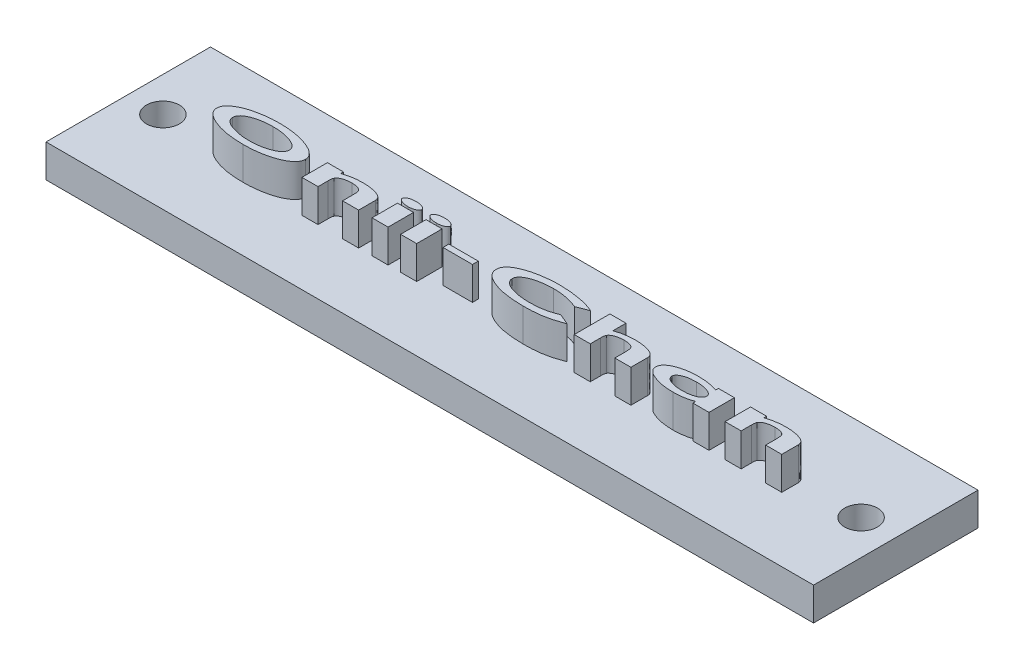
from build123d import *

# Parameters (mm, degrees)
SKETCH3_W           = 70
SKETCH3_H           = 15
BOSS_EXTRUDE2_DEPTH = 3
SKETCH4_W           = 1.465384615
SKETCH4_H           = 2.320192308
SKETCH4_W_2         = 2.686538461
SKETCH4_H_2         = 0.529166666
BOSS_EXTRUDE3_DEPTH = 3
CUT_EXTRUDE1_DEPTH  = 3


with BuildPart() as part:
    # Sketch3 → Boss-Extrude2 (new body)
    with BuildSketch(Plane(origin=(0, 0, 0), x_dir=(1, 0, 0), z_dir=(0, 1, 0))):
        Rectangle(SKETCH3_W, SKETCH3_H)
    extrude(amount=BOSS_EXTRUDE2_DEPTH)

    # Sketch4 → Boss-Extrude3 (add)
    with BuildSketch(Plane(origin=(0, 3, 0), x_dir=(1, 0, 0), z_dir=(0, 1, 0))):
        with BuildLine():
            add(Edge.make_bspline(
                [(-22.825846191, 1.629736401), (-22.757576293, 1.629374686), (-22.622072425, 1.628656742), (-22.420627484, 1.622767894), (-22.222784263, 1.613313748), (-22.028752902, 1.599985882), (-21.838329126, 1.582800798), (-21.651494379, 1.561901541), (-21.468068408, 1.537041789), (-21.288416269, 1.508604489), (-21.11242193, 1.476023598), (-20.940187047, 1.439906436), (-20.771392926, 1.399739372), (-20.606143448, 1.355981818), (-20.444525265, 1.308278732), (-20.286710423, 1.256789692), (-20.132543975, 1.201350028), (-19.982823493, 1.142566676), (-19.839183362, 1.081606322), (-19.704420123, 1.01784352), (-19.578383841, 0.953269033), (-19.46255587, 0.885630247), (-19.354796082, 0.818048497), (-19.257595324, 0.747061496), (-19.168943381, 0.67547058), (-19.089274699, 0.602102951), (-19.019683423, 0.526524233), (-18.958134502, 0.44996964), (-18.907486128, 0.370746496), (-18.864755173, 0.290415565), (-18.832412655, 0.207921761), (-18.808498405, 0.124096231), (-18.793989339, 0.038291112), (-18.792390068, -0.01961446), (-18.791586376, -0.048714119)],
                knots=[0, 0, 0, 0, 0.000204807, 0.000406505, 0.000604537, 0.000798981, 0.000989924, 0.001178088, 0.001362933, 0.001545187, 0.0017237, 0.001899832, 0.002073074, 0.002244163, 0.002412607, 0.002578539, 0.002742099, 0.002904026, 0.00306103, 0.003210114, 0.003351208, 0.003485715, 0.003612397, 0.00373262, 0.003846554, 0.003954116, 0.004057184, 0.004154528, 0.004248384, 0.00433885, 0.004427076, 0.004513654, 0.004600021, 0.004687269, 0.004687269, 0.004687269, 0.004687269], degree=3))
            add(Edge.make_bspline(
                [(-18.791586376, -0.048714119), (-18.792385512, -0.077393448), (-18.793981574, -0.134672739), (-18.808666166, -0.219519636), (-18.831696145, -0.302811901), (-18.863568531, -0.384591507), (-18.905214307, -0.464514415), (-18.956803822, -0.542013232), (-19.015947485, -0.618853731), (-19.085098278, -0.69335278), (-19.163837502, -0.765645989), (-19.251019028, -0.837232258), (-19.348097378, -0.905924498), (-19.453261674, -0.974687167), (-19.568351789, -1.040114017), (-19.692264151, -1.104569155), (-19.825198233, -1.167574579), (-19.966939336, -1.227853291), (-20.114761842, -1.286362895), (-20.267780806, -1.340024133), (-20.424157538, -1.39112695), (-20.584713055, -1.438235), (-20.749145411, -1.481234079), (-20.917482405, -1.520932162), (-21.089813158, -1.556116979), (-21.265878623, -1.589064461), (-21.446089108, -1.616420668), (-21.630019602, -1.641862794), (-21.818034284, -1.661467152), (-22.009846259, -1.679295187), (-22.20564539, -1.691400339), (-22.405358766, -1.701186388), (-22.60892962, -1.706992203), (-22.745916419, -1.707717938), (-22.815033892, -1.708084111)],
                knots=[0, 0, 0, 0, 8.5978e-05, 0.000171718, 0.000257512, 0.000344913, 0.000434521, 0.00052731, 0.000623869, 0.00072514, 0.000831804, 0.00094435, 0.001063312, 0.00118839, 0.001321159, 0.001460267, 0.001607353, 0.001762354, 0.001922272, 0.002084206, 0.002248732, 0.002415776, 0.002586088, 0.002758565, 0.002934567, 0.003113705, 0.00329586, 0.003481336, 0.003670694, 0.003862904, 0.00405921, 0.004259147, 0.004462753, 0.004670104, 0.004670104, 0.004670104, 0.004670104], degree=3))
            add(Edge.make_bspline(
                [(-22.815033892, -1.708084111), (-22.887332117, -1.70773091), (-23.030467403, -1.707031644), (-23.242929166, -1.701055372), (-23.450771295, -1.691932197), (-23.653857906, -1.677494606), (-23.852369851, -1.660595817), (-24.046453066, -1.639767549), (-24.235808577, -1.614314616), (-24.42042837, -1.584778074), (-24.600451363, -1.552910079), (-24.775721312, -1.515597575), (-24.946514672, -1.475180414), (-25.11260521, -1.430693807), (-25.273948351, -1.382137005), (-25.430797426, -1.330273951), (-25.583065036, -1.274180436), (-25.729818817, -1.214720263), (-25.869927638, -1.152798469), (-26.001463168, -1.088718121), (-26.123846325, -1.023096666), (-26.237452456, -0.956507261), (-26.341784999, -0.887777424), (-26.437419563, -0.817864219), (-26.52415639, -0.746839363), (-26.60161702, -0.674054823), (-26.669934427, -0.599844543), (-26.72862247, -0.523583327), (-26.779440036, -0.446834987), (-26.820396018, -0.367913003), (-26.852663752, -0.287696448), (-26.874528242, -0.205620284), (-26.889616439, -0.122409678), (-26.891140844, -0.06616559), (-26.891906889, -0.03790182)],
                knots=[0, 0, 0, 0, 0.00021689, 0.000429397, 0.000637594, 0.000840965, 0.001040145, 0.001235262, 0.001426495, 0.001613246, 0.001796139, 0.001974891, 0.002150756, 0.002322623, 0.002490639, 0.002656166, 0.002818151, 0.002977358, 0.003131118, 0.00327761, 0.003416187, 0.003547627, 0.00367252, 0.003790826, 0.003902881, 0.004008615, 0.004109455, 0.004205123, 0.004297031, 0.004385218, 0.004471435, 0.004555834, 0.004639692, 0.004724399, 0.004724399, 0.004724399, 0.004724399], degree=3))
            add(Edge.make_bspline(
                [(-26.891906889, -0.03790182), (-26.890356623, -0.000234642), (-26.887246817, 0.075325058), (-26.860513312, 0.187069583), (-26.817372632, 0.296089814), (-26.757138327, 0.402428191), (-26.68083959, 0.506660397), (-26.586819306, 0.607940414), (-26.476363464, 0.707080575), (-26.349517804, 0.803042465), (-26.208849851, 0.896558808), (-26.053664848, 0.983571984), (-25.886682415, 1.067385149), (-25.706609041, 1.145117723), (-25.513995744, 1.218108164), (-25.309217291, 1.287026797), (-25.091243492, 1.349435376), (-24.862191285, 1.407623643), (-24.624707586, 1.460256163), (-24.3810594, 1.505033801), (-24.133241783, 1.544298766), (-23.880500198, 1.574819383), (-23.6233289, 1.600255618), (-23.361533969, 1.616618781), (-23.095200525, 1.628328677), (-22.916174015, 1.629264322), (-22.825846191, 1.629736401)],
                knots=[0, 0, 0, 0, 0.000112878, 0.000226432, 0.000342649, 0.000463668, 0.000592027, 0.00072932, 0.00087748, 0.001036745, 0.001206089, 0.001383825, 0.00157013, 0.001766389, 0.001971921, 0.002187931, 0.002414379, 0.002651937, 0.002896837, 0.003143956, 0.003395019, 0.003649434, 0.00390758, 0.004170181, 0.004436256, 0.004707218, 0.004707218, 0.004707218, 0.004707218], degree=3))
        make_face()
        with BuildLine():
            add(Edge.make_bspline(
                [(-22.846834773, 1.059864607), (-22.936111049, 1.058892233), (-23.110970178, 1.056987714), (-23.3679062, 1.041929777), (-23.613939617, 1.018409889), (-23.849273671, 0.983861989), (-24.073712984, 0.940322618), (-24.287447867, 0.88708925), (-24.490061827, 0.823534341), (-24.650596183, 0.76200268), (-24.772211495, 0.709662079), (-24.856023662, 0.667850939), (-24.934777907, 0.626253333), (-25.007198172, 0.582212387), (-25.074203639, 0.537186166), (-25.135175835, 0.490667984), (-25.191083164, 0.443635058), (-25.240754713, 0.394818837), (-25.284125037, 0.344067663), (-25.322644214, 0.292852764), (-25.354735924, 0.239537882), (-25.380707052, 0.184918916), (-25.401304881, 0.129184779), (-25.416265074, 0.072156928), (-25.424330734, 0.013634115), (-25.425791183, -0.025795748), (-25.426522273, -0.045534031)],
                knots=[0, 0, 0, 0, 0.000267812, 0.000524544, 0.000771867, 0.001009057, 0.00123782, 0.001457482, 0.0016695, 0.001874438, 0.001972986, 0.002066567, 0.002155348, 0.0022401, 0.002320717, 0.002397422, 0.002470065, 0.002539775, 0.00260607, 0.002670182, 0.00273181, 0.002792405, 0.002851363, 0.002909829, 0.002968923, 0.003028158, 0.003028158, 0.003028158, 0.003028158], degree=3))
            add(Edge.make_bspline(
                [(-25.426522273, -0.045534031), (-25.425747619, -0.067624473), (-25.424211341, -0.111433785), (-25.413108921, -0.176378748), (-25.39448007, -0.239430423), (-25.368999728, -0.30102726), (-25.335501585, -0.360288148), (-25.295017488, -0.417993278), (-25.247352564, -0.473817301), (-25.19195391, -0.527571091), (-25.129372393, -0.579449121), (-25.060165461, -0.630716043), (-24.982612544, -0.678531338), (-24.898629896, -0.72594387), (-24.806934755, -0.770750363), (-24.708095741, -0.814132305), (-24.601832357, -0.855260332), (-24.528122334, -0.880851581), (-24.490304324, -0.893981547)],
                knots=[0, 0, 0, 0, 6.6256e-05, 0.000131397, 0.000197009, 0.000263155, 0.000330923, 0.000400795, 0.000474334, 0.000550794, 0.000632065, 0.000718059, 0.000808938, 0.000905185, 0.001007299, 0.001114952, 0.001228929, 0.001349021, 0.001349021, 0.001349021, 0.001349021], degree=3))
            add(Edge.make_bspline(
                [(-24.490304324, -0.893981547), (-24.428576808, -0.913670252), (-24.303837952, -0.953457151), (-24.111364207, -1.002494157), (-23.912568691, -1.044630591), (-23.706921232, -1.078833754), (-23.494523964, -1.105449107), (-23.275573893, -1.124337306), (-23.050066437, -1.136103156), (-22.897518728, -1.137502397), (-22.820122033, -1.138212317)],
                knots=[0, 0, 0, 0, 0.000194339, 0.000392719, 0.000595548, 0.000803833, 0.001017935, 0.001237556, 0.001462997, 0.001695175, 0.001695175, 0.001695175, 0.001695175], degree=3))
            add(Edge.make_bspline(
                [(-22.820122033, -1.138212317), (-22.732967892, -1.137211669), (-22.561926486, -1.135247882), (-22.310232518, -1.120514757), (-22.068541046, -1.095790292), (-21.836480331, -1.06170982), (-21.614344867, -1.017425241), (-21.402097355, -0.962565795), (-21.199624151, -0.898571477), (-21.038487603, -0.836808785), (-20.916549154, -0.783389362), (-20.831726251, -0.741916018), (-20.752704792, -0.699413705), (-20.679632255, -0.655462267), (-20.611916505, -0.611023093), (-20.550064654, -0.565468021), (-20.494515092, -0.517935732), (-20.444075157, -0.470004549), (-20.400082839, -0.420368425), (-20.362357356, -0.36952792), (-20.329183273, -0.318169), (-20.303830867, -0.264523391), (-20.281863232, -0.210730362), (-20.267385625, -0.155140331), (-20.259131246, -0.098360218), (-20.257691594, -0.06018841), (-20.256970991, -0.041081908)],
                knots=[0, 0, 0, 0, 0.000261453, 0.000513105, 0.000756061, 0.000990106, 0.001216497, 0.00143524, 0.001647449, 0.001853209, 0.001952594, 0.002046747, 0.002136389, 0.002221686, 0.002302478, 0.00237931, 0.002451953, 0.002521674, 0.002587909, 0.00265062, 0.002711499, 0.002770949, 0.002828349, 0.002885583, 0.00294279, 0.003000119, 0.003000119, 0.003000119, 0.003000119], degree=3))
            add(Edge.make_bspline(
                [(-20.256970991, -0.041081908), (-20.257621671, -0.021967726), (-20.25891558, 0.016041777), (-20.268120016, 0.072331242), (-20.282974005, 0.12743897), (-20.302989613, 0.181665828), (-20.330645259, 0.234190818), (-20.362602855, 0.2862701), (-20.401492897, 0.336867545), (-20.445739071, 0.386407536), (-20.496874342, 0.434033061), (-20.552313036, 0.481919585), (-20.614758048, 0.527673653), (-20.682624735, 0.57274897), (-20.756563007, 0.616559008), (-20.836162496, 0.65916085), (-20.921789568, 0.700473864), (-21.044536581, 0.755051003), (-21.206981941, 0.817629432), (-21.411374168, 0.882466361), (-21.625524263, 0.937883043), (-21.85031353, 0.98203117), (-22.085066988, 1.016804692), (-22.329918178, 1.042336986), (-22.585041171, 1.056864551), (-22.758410115, 1.058851294), (-22.846834773, 1.059864607)],
                knots=[0, 0, 0, 0, 5.733e-05, 0.000114003, 0.000170623, 0.000228389, 0.000286985, 0.000348403, 0.000411497, 0.000478155, 0.000547437, 0.000620976, 0.000697808, 0.000779481, 0.000865325, 0.000955527, 0.001050251, 0.001150476, 0.001358473, 0.001572088, 0.001793453, 0.002021715, 0.002258998, 0.002505183, 0.00276001, 0.003025279, 0.003025279, 0.003025279, 0.003025279], degree=3))
        make_face(mode=Mode.SUBTRACT)
        with BuildLine():
            Line((-17.529727401, 0.693518453), (-16.064342786, 0.693518453))
            Line((-16.064342786, 0.693518453), (-16.064342786, 0.448015648))
            add(Edge.make_bspline(
                [(-16.064342786, 0.448015648), (-15.983541717, 0.473446925), (-15.826748889, 0.5227958), (-15.595373439, 0.584352394), (-15.376066534, 0.634351317), (-15.165967175, 0.672578169), (-14.960443206, 0.699934757), (-14.754871618, 0.719558809), (-14.546964126, 0.732208209), (-14.407534894, 0.733550088), (-14.337554925, 0.734223581)],
                knots=[0, 0, 0, 0, 0.000254099, 0.000493074, 0.000718039, 0.000928749, 0.001133473, 0.001339851, 0.001548179, 0.0017581, 0.0017581, 0.0017581, 0.0017581], degree=3))
            add(Edge.make_bspline(
                [(-14.337554925, 0.734223581), (-14.266733764, 0.733438665), (-14.127763565, 0.731898447), (-13.923377181, 0.721347715), (-13.727378058, 0.701998455), (-13.539275716, 0.67629869), (-13.359534074, 0.642570706), (-13.187632708, 0.60208729), (-13.024071855, 0.553457668), (-12.919246511, 0.514319736), (-12.867718187, 0.495080953)],
                knots=[0, 0, 0, 0, 0.000212464, 0.000416912, 0.000613732, 0.000803161, 0.000986283, 0.001162148, 0.001332783, 0.001497756, 0.001497756, 0.001497756, 0.001497756], degree=3))
            add(Edge.make_bspline(
                [(-12.867718187, 0.495080953), (-12.827680584, 0.477874566), (-12.751136288, 0.444979221), (-12.647365988, 0.384903537), (-12.558910556, 0.319204098), (-12.485837399, 0.247222015), (-12.429251089, 0.167798497), (-12.389644357, 0.081900015), (-12.363993384, -0.009718962), (-12.361461209, -0.073135528), (-12.360176119, -0.105319688)],
                knots=[0, 0, 0, 0, 0.000130646, 0.000249769, 0.000358783, 0.000460422, 0.000556244, 0.000649574, 0.000743066, 0.000839408, 0.000839408, 0.000839408, 0.000839408], degree=3))
            Line((-12.360176119, -0.105319688), (-12.360176119, -1.626673855))
            Line((-12.360176119, -1.626673855), (-13.825560735, -1.626673855))
            Line((-13.825560735, -1.626673855), (-13.825560735, -0.619221932))
            add(Edge.make_bspline(
                [(-13.825560735, -0.619221932), (-13.825749957, -0.58635767), (-13.826112728, -0.523351454), (-13.830341307, -0.433141912), (-13.838348727, -0.35175928), (-13.847009848, -0.278710762), (-13.860588547, -0.214637726), (-13.875900888, -0.158826901), (-13.895020665, -0.111912396), (-13.917085537, -0.072209331), (-13.943477186, -0.038586295), (-13.973024798, -0.007595847), (-14.007250488, 0.020903783), (-14.044993488, 0.048579196), (-14.088426401, 0.07236104), (-14.135250561, 0.095257792), (-14.18632272, 0.116453052), (-14.262228872, 0.141212518), (-14.366272081, 0.167725159), (-14.502284805, 0.189366859), (-14.651688691, 0.202805096), (-14.755811606, 0.204285055), (-14.810116023, 0.205056914)],
                knots=[0, 0, 0, 0, 9.8591e-05, 0.000189015, 0.000270782, 0.000343913, 0.000409525, 0.000467098, 0.000517295, 0.000561157, 0.000602883, 0.000645167, 0.000689388, 0.000736337, 0.000785327, 0.000837666, 0.000892706, 0.000951033, 0.001077062, 0.001214351, 0.001363777, 0.001526658, 0.001526658, 0.001526658, 0.001526658], degree=3))
            add(Edge.make_bspline(
                [(-14.810116023, 0.205056914), (-14.845954053, 0.204715431), (-14.916616659, 0.204042121), (-15.020544177, 0.197990521), (-15.120727371, 0.189405659), (-15.217064343, 0.176598219), (-15.309638743, 0.160271471), (-15.398385958, 0.139921322), (-15.482993634, 0.115626968), (-15.563545154, 0.088540215), (-15.639136362, 0.058373442), (-15.708671837, 0.024454113), (-15.772460484, -0.011786632), (-15.830723994, -0.050343572), (-15.882361654, -0.092450029), (-15.927999294, -0.137310815), (-15.967803869, -0.184979375), (-15.989845098, -0.219348959), (-16.000741023, -0.23633932)],
                knots=[0, 0, 0, 0, 0.000107504, 0.000211968, 0.000312219, 0.000409096, 0.000503416, 0.000594135, 0.00068211, 0.000767388, 0.000849, 0.000926086, 0.000999295, 0.001068973, 0.001135427, 0.001198841, 0.001260731, 0.001321236, 0.001321236, 0.001321236, 0.001321236], degree=3))
            add(Edge.make_bspline(
                [(-16.000741023, -0.23633932), (-16.005836756, -0.246632303), (-16.017005778, -0.269192854), (-16.030066462, -0.308247488), (-16.040476042, -0.354968894), (-16.049319551, -0.40934334), (-16.056064419, -0.471763442), (-16.061211829, -0.541973897), (-16.06332814, -0.620058117), (-16.063993401, -0.674555197), (-16.064342786, -0.703176259)],
                knots=[0, 0, 0, 0, 3.4427e-05, 7.5459e-05, 0.000123131, 0.000177921, 0.000240642, 0.000311423, 0.000389059, 0.00047493, 0.00047493, 0.00047493, 0.00047493], degree=3))
            Line((-16.064342786, -0.703176259), (-16.064342786, -1.626673855))
            Line((-16.064342786, -1.626673855), (-17.529727401, -1.626673855))
            Line((-17.529727401, -1.626673855), (-17.529727401, 0.693518453))
        make_face()
        with BuildLine():
            add(Edge.make_bspline(
                [(-10.408874036, 1.67044153), (-10.37855075, 1.670032325), (-10.319133398, 1.669230504), (-10.231683927, 1.664199011), (-10.147412092, 1.655328707), (-10.066570771, 1.64264461), (-9.988803771, 1.626809124), (-9.914592173, 1.606937782), (-9.843227669, 1.584441512), (-9.776294201, 1.557621746), (-9.714785657, 1.52932506), (-9.660942448, 1.49841899), (-9.61450401, 1.46727815), (-9.577394593, 1.432958193), (-9.546996156, 1.398203261), (-9.526719236, 1.360460769), (-9.512689936, 1.321825432), (-9.511438232, 1.295097141), (-9.510817145, 1.281834759)],
                knots=[0, 0, 0, 0, 9.0971e-05, 0.000178253, 0.000262679, 0.000345077, 0.00042366, 0.000500642, 0.000575465, 0.000647983, 0.000716837, 0.00077837, 0.000834122, 0.000884093, 0.000929696, 0.000971827, 0.001012052, 0.00105167, 0.00105167, 0.00105167, 0.00105167], degree=3))
            add(Edge.make_bspline(
                [(-9.510817145, 1.281834759), (-9.511419968, 1.2685688), (-9.512625692, 1.242035174), (-9.526709603, 1.203804936), (-9.547062961, 1.166918666), (-9.576907304, 1.132356274), (-9.613808949, 1.098499417), (-9.659630743, 1.067144314), (-9.712728522, 1.036172621), (-9.773771542, 1.008599875), (-9.840166696, 0.98252498), (-9.910572733, 0.959971851), (-9.983906604, 0.939994586), (-10.060581238, 0.924079989), (-10.140683363, 0.912319812), (-10.223832291, 0.903264409), (-10.310229894, 0.898263004), (-10.368798948, 0.897456039), (-10.398697754, 0.897044094)],
                knots=[0, 0, 0, 0, 3.9617e-05, 7.924e-05, 0.000120815, 0.000165522, 0.000215493, 0.000270724, 0.000331706, 0.000399715, 0.000471407, 0.000545625, 0.000621378, 0.000699339, 0.000780383, 0.000864176, 0.000950189, 0.001039888, 0.001039888, 0.001039888, 0.001039888], degree=3))
            add(Edge.make_bspline(
                [(-10.398697754, 0.897044094), (-10.429444851, 0.897454981), (-10.48970921, 0.898260322), (-10.578219999, 0.903259789), (-10.663339529, 0.912147193), (-10.745012241, 0.924919825), (-10.823446431, 0.940564809), (-10.898211379, 0.960335301), (-10.9694445, 0.984032315), (-11.036740217, 1.010122411), (-11.098243609, 1.039125723), (-11.15222536, 1.069927947), (-11.19824199, 1.102348493), (-11.235346742, 1.13703621), (-11.265473807, 1.172399858), (-11.286119547, 1.210344599), (-11.299948313, 1.249505051), (-11.301214307, 1.276634893), (-11.301842786, 1.290102988)],
                knots=[0, 0, 0, 0, 9.2242e-05, 0.000180795, 0.000265853, 0.000348879, 0.000428709, 0.000505691, 0.000580711, 0.00065382, 0.000722099, 0.0007845, 0.0008401, 0.000890502, 0.000936595, 0.000978726, 0.001019555, 0.001059806, 0.001059806, 0.001059806, 0.001059806], degree=3))
            add(Edge.make_bspline(
                [(-11.301842786, 1.290102988), (-11.301244719, 1.303160864), (-11.300048029, 1.329288774), (-11.285803785, 1.367031287), (-11.265559978, 1.403689103), (-11.236166974, 1.438362589), (-11.198397194, 1.470507388), (-11.153767024, 1.502861473), (-11.099896858, 1.531980068), (-11.039312421, 1.560607597), (-10.972600677, 1.585973962), (-10.902018717, 1.609073355), (-10.828075398, 1.628091211), (-10.750733853, 1.643248486), (-10.670074433, 1.655208142), (-10.586070073, 1.664239889), (-10.498613097, 1.669219632), (-10.439196789, 1.670028651), (-10.408874036, 1.67044153)],
                knots=[0, 0, 0, 0, 3.8984e-05, 7.8005e-05, 0.00011958, 0.000164287, 0.000213409, 0.000268121, 0.000329341, 0.000396774, 0.000469059, 0.000543278, 0.000619483, 0.00069794, 0.000779613, 0.000864039, 0.000951322, 0.001042292, 0.001042292, 0.001042292, 0.001042292], degree=3))
        make_face()
        with Locations((-10.406329965, -0.466577701)):
            Rectangle(SKETCH4_W, SKETCH4_H)
        with BuildLine():
            add(Edge.make_bspline(
                [(-7.803745831, 1.67044153), (-7.773422545, 1.670032325), (-7.714005193, 1.669230504), (-7.626555722, 1.664199011), (-7.542283887, 1.655328707), (-7.461442566, 1.64264461), (-7.383675566, 1.626809124), (-7.309463968, 1.606937782), (-7.238099463, 1.584441512), (-7.171165996, 1.557621746), (-7.109657452, 1.52932506), (-7.055814243, 1.49841899), (-7.009375805, 1.46727815), (-6.972266388, 1.432958193), (-6.941867951, 1.398203261), (-6.921591031, 1.360460769), (-6.907561731, 1.321825432), (-6.906310026, 1.295097141), (-6.90568894, 1.281834759)],
                knots=[0, 0, 0, 0, 9.0971e-05, 0.000178253, 0.000262679, 0.000345077, 0.00042366, 0.000500642, 0.000575465, 0.000647983, 0.000716837, 0.00077837, 0.000834122, 0.000884093, 0.000929696, 0.000971827, 0.001012052, 0.00105167, 0.00105167, 0.00105167, 0.00105167], degree=3))
            add(Edge.make_bspline(
                [(-6.90568894, 1.281834759), (-6.906291763, 1.2685688), (-6.907497487, 1.242035174), (-6.921581398, 1.203804936), (-6.941934755, 1.166918666), (-6.971779099, 1.132356274), (-7.008680744, 1.098499417), (-7.054502538, 1.067144314), (-7.107600317, 1.036172621), (-7.168643337, 1.008599875), (-7.235038491, 0.98252498), (-7.305444528, 0.959971851), (-7.378778399, 0.939994586), (-7.455453033, 0.924079989), (-7.535555158, 0.912319812), (-7.618704085, 0.903264409), (-7.705101689, 0.898263004), (-7.763670742, 0.897456039), (-7.793569549, 0.897044094)],
                knots=[0, 0, 0, 0, 3.9617e-05, 7.924e-05, 0.000120815, 0.000165522, 0.000215493, 0.000270724, 0.000331706, 0.000399715, 0.000471407, 0.000545625, 0.000621378, 0.000699339, 0.000780383, 0.000864176, 0.000950189, 0.001039888, 0.001039888, 0.001039888, 0.001039888], degree=3))
            add(Edge.make_bspline(
                [(-7.793569549, 0.897044094), (-7.824316646, 0.897454981), (-7.884581005, 0.898260322), (-7.973091794, 0.903259789), (-8.058211324, 0.912147193), (-8.139884036, 0.924919825), (-8.218318226, 0.940564809), (-8.293083174, 0.960335301), (-8.364316295, 0.984032315), (-8.431612012, 1.010122411), (-8.493115404, 1.039125723), (-8.547097155, 1.069927947), (-8.593113785, 1.102348493), (-8.630218537, 1.13703621), (-8.660345602, 1.172399858), (-8.680991342, 1.210344599), (-8.694820108, 1.249505051), (-8.696086102, 1.276634893), (-8.696714581, 1.290102988)],
                knots=[0, 0, 0, 0, 9.2242e-05, 0.000180795, 0.000265853, 0.000348879, 0.000428709, 0.000505691, 0.000580711, 0.00065382, 0.000722099, 0.0007845, 0.0008401, 0.000890502, 0.000936595, 0.000978726, 0.001019555, 0.001059806, 0.001059806, 0.001059806, 0.001059806], degree=3))
            add(Edge.make_bspline(
                [(-8.696714581, 1.290102988), (-8.696116514, 1.303160864), (-8.694919824, 1.329288774), (-8.68067558, 1.367031287), (-8.660431773, 1.403689103), (-8.631038769, 1.438362589), (-8.593268989, 1.470507388), (-8.548638819, 1.502861473), (-8.494768653, 1.531980068), (-8.434184216, 1.560607597), (-8.367472472, 1.585973962), (-8.296890512, 1.609073355), (-8.222947193, 1.628091211), (-8.145605647, 1.643248486), (-8.064946228, 1.655208142), (-7.980941868, 1.664239889), (-7.893484892, 1.669219632), (-7.834068584, 1.670028651), (-7.803745831, 1.67044153)],
                knots=[0, 0, 0, 0, 3.8984e-05, 7.8005e-05, 0.00011958, 0.000164287, 0.000213409, 0.000268121, 0.000329341, 0.000396774, 0.000469059, 0.000543278, 0.000619483, 0.00069794, 0.000779613, 0.000864039, 0.000951322, 0.001042292, 0.001042292, 0.001042292, 0.001042292], degree=3))
        make_face()
        with Locations((-7.801201761, -0.466577701)):
            Rectangle(SKETCH4_W, SKETCH4_H)
        with Locations((-4.219150479, -0.466577701)):
            Rectangle(SKETCH4_W_2, SKETCH4_H_2)
        with BuildLine():
            Line((6.160657214, 0.997534879), (5.116316268, 0.598115808))
            add(Edge.make_bspline(
                [(5.116316268, 0.598115808), (5.02661141, 0.635192878), (4.846116513, 0.709795548), (4.566675359, 0.803310726), (4.278770025, 0.881951516), (3.983055529, 0.947976753), (3.678447404, 0.997654908), (3.36585594, 1.033907052), (3.044918313, 1.056078897), (2.828172067, 1.05859289), (2.71852981, 1.059864607)],
                knots=[0, 0, 0, 0, 0.00029113, 0.000585782, 0.00088327, 0.001186187, 0.001494328, 0.00180871, 0.002129991, 0.002458887, 0.002458887, 0.002458887, 0.002458887], degree=3))
            add(Edge.make_bspline(
                [(2.71852981, 1.059864607), (2.626712981, 1.058860226), (2.446564495, 1.05688959), (2.181941667, 1.042244117), (1.92839761, 1.017427215), (1.685715324, 0.983514352), (1.454165461, 0.938964897), (1.233420796, 0.88521207), (1.024080514, 0.820942603), (0.857750082, 0.759335584), (0.732503422, 0.705455853), (0.644876088, 0.665173689), (0.564229617, 0.622144141), (0.488864856, 0.579095078), (0.419486958, 0.53475598), (0.356265976, 0.488793522), (0.299069613, 0.441925352), (0.247741111, 0.394016136), (0.202408309, 0.344947701), (0.162708682, 0.294774347), (0.12936258, 0.24306547), (0.102510035, 0.189898645), (0.081514958, 0.135763191), (0.065895194, 0.080687606), (0.056870764, 0.024301696), (0.055551442, -0.013702278), (0.054887983, -0.032813679)],
                knots=[0, 0, 0, 0, 0.000275443, 0.00054043, 0.000794777, 0.001039522, 0.001275274, 0.00150188, 0.001720768, 0.001931881, 0.0020336, 0.002129773, 0.002221099, 0.002307719, 0.002390109, 0.002467966, 0.002542072, 0.002611817, 0.002678432, 0.002742304, 0.002803524, 0.002862687, 0.00292068, 0.002977467, 0.003034141, 0.003091471, 0.003091471, 0.003091471, 0.003091471], degree=3))
            add(Edge.make_bspline(
                [(0.054887983, -0.032813679), (0.055708275, -0.059418671), (0.057339075, -0.112311349), (0.075381266, -0.189881339), (0.100840867, -0.265848715), (0.139357469, -0.338492945), (0.187441894, -0.40940429), (0.247342922, -0.476898113), (0.316235505, -0.543838335), (0.396628242, -0.606778697), (0.486462298, -0.667120474), (0.585234558, -0.724113587), (0.69259321, -0.77843), (0.808808442, -0.829000718), (0.934113422, -0.87612336), (1.068124125, -0.919679669), (1.210911668, -0.96033738), (1.361647871, -0.997897474), (1.519245392, -1.030198145), (1.681547249, -1.059977899), (1.848356308, -1.083859898), (2.019549426, -1.103318266), (2.194874411, -1.119659436), (2.374567439, -1.12982049), (2.558398465, -1.137520811), (2.682480181, -1.137980035), (2.745242551, -1.138212317)],
                knots=[0, 0, 0, 0, 7.9665e-05, 0.00015838, 0.000237831, 0.000319472, 0.000404148, 0.000494315, 0.000589675, 0.000691985, 0.000800119, 0.000914115, 0.001033864, 0.001160891, 0.00129414, 0.001435333, 0.001583501, 0.001739456, 0.00190124, 0.002066043, 0.002234423, 0.002406644, 0.002582903, 0.002762586, 0.002946528, 0.003134799, 0.003134799, 0.003134799, 0.003134799], degree=3))
            add(Edge.make_bspline(
                [(2.745242551, -1.138212317), (2.851271205, -1.136975505), (3.059040952, -1.134551895), (3.363611182, -1.116057632), (3.654147673, -1.084999033), (3.888110123, -1.048780184), (4.071686012, -1.012274416), (4.21100378, -0.97858446), (4.354083216, -0.941394477), (4.500354938, -0.898545825), (4.650010466, -0.851039896), (4.802390267, -0.797146899), (4.958620495, -0.739485208), (5.063195539, -0.697692737), (5.116316268, -0.676463518)],
                knots=[0, 0, 0, 0, 0.000318072, 0.000623283, 0.000914976, 0.001194376, 0.001333204, 0.001476364, 0.001624306, 0.001776671, 0.001933562, 0.002095286, 0.002261512, 0.002433121, 0.002433121, 0.002433121, 0.002433121], degree=3))
            Line((5.116316268, -0.676463518), (6.128856333, -1.101959312))
            add(Edge.make_bspline(
                [(6.128856333, -1.101959312), (6.057321987, -1.129636762), (5.915679787, -1.184439738), (5.703602037, -1.259931401), (5.494364034, -1.328601528), (5.288479269, -1.391971404), (5.085253901, -1.447840752), (4.884920257, -1.496686858), (4.688077743, -1.540399561), (4.492185447, -1.576643225), (4.294558436, -1.608241152), (4.091737543, -1.634542314), (3.882067212, -1.657774905), (3.665498656, -1.675754519), (3.442242986, -1.690663572), (3.212147544, -1.700447871), (2.975309722, -1.707208094), (2.814997463, -1.707789574), (2.733794233, -1.708084111)],
                knots=[0, 0, 0, 0, 0.000230099, 0.000455609, 0.00067524, 0.000890715, 0.001101796, 0.001307423, 0.001509276, 0.00170662, 0.001904977, 0.002109618, 0.002320116, 0.002537781, 0.002761502, 0.00299133, 0.00322865, 0.003472252, 0.003472252, 0.003472252, 0.003472252], degree=3))
            add(Edge.make_bspline(
                [(2.733794233, -1.708084111), (2.658739822, -1.707742016), (2.510304967, -1.707065455), (2.290224492, -1.700946735), (2.075199326, -1.692363921), (1.865483732, -1.679633109), (1.660846241, -1.663169802), (1.46156627, -1.642632099), (1.267198417, -1.619616501), (1.078379276, -1.591154617), (0.894412944, -1.560406903), (0.715746963, -1.525091813), (0.541828308, -1.48748253), (0.373430478, -1.444411502), (0.209937268, -1.399056449), (0.051768372, -1.349193415), (-0.101131046, -1.295893875), (-0.248504429, -1.23965608), (-0.388394178, -1.17998383), (-0.520323843, -1.118808153), (-0.642358874, -1.054156439), (-0.756142666, -0.988953369), (-0.860740634, -0.920940364), (-0.955936543, -0.85019164), (-1.043198195, -0.778674001), (-1.120193837, -0.703861666), (-1.188785325, -0.627758262), (-1.247390785, -0.548860545), (-1.298436731, -0.468789168), (-1.338988928, -0.385620063), (-1.371408508, -0.300808474), (-1.393190367, -0.213633681), (-1.408234936, -0.12470805), (-1.409738425, -0.064465814), (-1.410496632, -0.034085714)],
                knots=[0, 0, 0, 0, 0.000225158, 0.000445295, 0.000660453, 0.000870724, 0.001075554, 0.001276298, 0.001471706, 0.001662665, 0.001849097, 0.002031209, 0.002208986, 0.002382834, 0.002552584, 0.002717934, 0.002880258, 0.003038299, 0.003191046, 0.003336439, 0.00347442, 0.003605219, 0.003729763, 0.003848446, 0.003960906, 0.004067958, 0.004170214, 0.004267907, 0.004362494, 0.004454653, 0.004545023, 0.00463434, 0.004723847, 0.004814907, 0.004814907, 0.004814907, 0.004814907], degree=3))
            add(Edge.make_bspline(
                [(-1.410496632, -0.034085714), (-1.408902023, 0.005049929), (-1.405715242, 0.083261359), (-1.38003788, 0.198405903), (-1.337883859, 0.309922197), (-1.279604503, 0.418037289), (-1.203758379, 0.522006256), (-1.113356991, 0.62386279), (-1.004296563, 0.720254985), (-0.88030256, 0.814145781), (-0.741008695, 0.904182776), (-0.586790874, 0.989192272), (-0.418850108, 1.070772347), (-0.235930224, 1.146560922), (-0.03917719, 1.218347396), (0.171761908, 1.285688218), (0.396929482, 1.348356791), (0.634719359, 1.406414361), (0.882013229, 1.458904453), (1.135709115, 1.504607205), (1.394053122, 1.543302055), (1.657001778, 1.575404338), (1.924747674, 1.598975874), (2.197208475, 1.617246506), (2.474436239, 1.62720511), (2.660857152, 1.628888333), (2.754782815, 1.629736401)],
                knots=[0, 0, 0, 0, 0.000117319, 0.000234458, 0.000352, 0.000474079, 0.000601692, 0.000737277, 0.000881843, 0.001037543, 0.001203548, 0.001378929, 0.001565533, 0.001763383, 0.001972642, 0.002193695, 0.002427484, 0.002673681, 0.002927906, 0.003185775, 0.003446897, 0.00371149, 0.003980342, 0.004253139, 0.00453063, 0.004812411, 0.004812411, 0.004812411, 0.004812411], degree=3))
            add(Edge.make_bspline(
                [(2.754782815, 1.629736401), (2.834927562, 1.629256823), (2.994617232, 1.628301256), (3.233172825, 1.620314303), (3.469660994, 1.608027873), (3.70369673, 1.589034505), (3.935374804, 1.56676522), (4.164484807, 1.537510115), (4.391746501, 1.50499279), (4.615805065, 1.466009232), (4.835189608, 1.423267466), (5.047401444, 1.375410382), (5.252272512, 1.324218081), (5.448953341, 1.267458836), (5.638305014, 1.207249808), (5.819648794, 1.142266991), (5.993629918, 1.073399388), (6.105518065, 1.022579315), (6.160657214, 0.997534879)],
                knots=[0, 0, 0, 0, 0.000240428, 0.000479057, 0.000715997, 0.000950777, 0.001183417, 0.001414165, 0.00164362, 0.001872088, 0.00209636, 0.00231408, 0.002524641, 0.002729771, 0.002928096, 0.003120621, 0.003307582, 0.003489239, 0.003489239, 0.003489239, 0.003489239], degree=3))
        make_face()
        with BuildLine():
            Line((7.300400804, 1.629736401), (8.765785419, 1.629736401))
            Line((8.765785419, 1.629736401), (8.765785419, 0.44229149))
            add(Edge.make_bspline(
                [(8.765785419, 0.44229149), (8.837038599, 0.465816774), (8.978682019, 0.51258243), (9.193827543, 0.571347509), (9.40928516, 0.62191916), (9.626009808, 0.662501266), (9.84349014, 0.694377603), (10.062246982, 0.717173792), (10.282061902, 0.731819581), (10.429160725, 0.733421961), (10.502749562, 0.734223581)],
                knots=[0, 0, 0, 0, 0.000225076, 0.000447425, 0.000668813, 0.000888856, 0.001108687, 0.001328039, 0.001548545, 0.001769289, 0.001769289, 0.001769289, 0.001769289], degree=3))
            add(Edge.make_bspline(
                [(10.502749562, 0.734223581), (10.573572805, 0.733462962), (10.712335375, 0.731972698), (10.916250205, 0.72111578), (11.111693495, 0.702831517), (11.298718564, 0.677014291), (11.477163591, 0.643152854), (11.64712081, 0.602772513), (11.808612704, 0.554751379), (11.911732274, 0.516022282), (11.962410018, 0.496989006)],
                knots=[0, 0, 0, 0, 0.000212464, 0.000416277, 0.000612403, 0.000801202, 0.000982449, 0.001157076, 0.001325092, 0.001487456, 0.001487456, 0.001487456, 0.001487456], degree=3))
            add(Edge.make_bspline(
                [(11.962410018, 0.496989006), (12.002474696, 0.479831225), (12.079169033, 0.446986717), (12.182781619, 0.386142372), (12.271277273, 0.319854754), (12.344133742, 0.24726834), (12.400706573, 0.167940164), (12.44062786, 0.082389563), (12.466168265, -0.009299215), (12.468675529, -0.072925026), (12.469952086, -0.105319688)],
                knots=[0, 0, 0, 0, 0.000130646, 0.00025009, 0.000359487, 0.000461577, 0.000557399, 0.000650152, 0.000743645, 0.00084062, 0.00084062, 0.00084062, 0.00084062], degree=3))
            Line((12.469952086, -0.105319688), (12.469952086, -1.626673855))
            Line((12.469952086, -1.626673855), (11.00456747, -1.626673855))
            Line((11.00456747, -1.626673855), (11.00456747, -0.617949897))
            add(Edge.make_bspline(
                [(11.00456747, -0.617949897), (11.004387284, -0.585932804), (11.004042227, -0.524620008), (10.999689608, -0.43653894), (10.991915483, -0.356592461), (10.982560795, -0.28438136), (10.968033654, -0.220887162), (10.952900223, -0.16470816), (10.933174339, -0.117005288), (10.910505712, -0.076038206), (10.883484189, -0.041141112), (10.853306957, -0.008886999), (10.818707581, 0.020748602), (10.780692136, 0.049167956), (10.737427085, 0.073736977), (10.690402408, 0.096489538), (10.639356835, 0.11772359), (10.563707664, 0.142479243), (10.459933102, 0.168086362), (10.324512661, 0.190326603), (10.175425214, 0.202518822), (10.071551046, 0.204187897), (10.017468111, 0.205056914)],
                knots=[0, 0, 0, 0, 9.6047e-05, 0.00018393, 0.000264431, 0.000337018, 0.000402141, 0.000459714, 0.000511329, 0.000556612, 0.000599734, 0.000643379, 0.000688911, 0.000736234, 0.00078554, 0.00083788, 0.00089292, 0.000951247, 0.001076503, 0.001213164, 0.001362535, 0.001524781, 0.001524781, 0.001524781, 0.001524781], degree=3))
            add(Edge.make_bspline(
                [(10.017468111, 0.205056914), (9.981635693, 0.204620257), (9.910995125, 0.203759423), (9.806978971, 0.199066573), (9.706889065, 0.189188616), (9.610793885, 0.176499041), (9.518299603, 0.161060084), (9.430139589, 0.140421683), (9.345575885, 0.116964943), (9.265297673, 0.089823042), (9.189888685, 0.059508298), (9.120315489, 0.026552771), (9.057048376, -0.009258899), (8.999285773, -0.047279394), (8.947977813, -0.088834829), (8.901543758, -0.131973598), (8.861703964, -0.178447158), (8.840049968, -0.21212405), (8.829387182, -0.228707108)],
                knots=[0, 0, 0, 0, 0.000107504, 0.000211935, 0.000312244, 0.000409122, 0.000502705, 0.000593424, 0.000680614, 0.000765893, 0.000847504, 0.000924315, 0.000996656, 0.001065452, 0.001131506, 0.001194494, 0.001255409, 0.001314504, 0.001314504, 0.001314504, 0.001314504], degree=3))
            add(Edge.make_bspline(
                [(8.829387182, -0.228707108), (8.824262764, -0.238562028), (8.812820358, -0.260567261), (8.800133723, -0.299374048), (8.789488359, -0.346455094), (8.780906368, -0.401519689), (8.774012936, -0.464973731), (8.768894889, -0.536675835), (8.766806577, -0.616878285), (8.766136714, -0.673071118), (8.765785419, -0.702540241)],
                knots=[0, 0, 0, 0, 3.328e-05, 7.4312e-05, 0.000121984, 0.000178029, 0.000241382, 0.000313432, 0.000393611, 0.000482026, 0.000482026, 0.000482026, 0.000482026], degree=3))
            Line((8.765785419, -0.702540241), (8.765785419, -1.626673855))
            Line((8.765785419, -1.626673855), (7.300400804, -1.626673855))
            Line((7.300400804, -1.626673855), (7.300400804, 1.629736401))
        make_face()
        with BuildLine():
            Line((18.127964906, 0.693518453), (19.593349522, 0.693518453))
            Line((19.593349522, 0.693518453), (19.593349522, -1.626673855))
            Line((19.593349522, -1.626673855), (18.127964906, -1.626673855))
            Line((18.127964906, -1.626673855), (18.127964906, -1.373538839))
            add(Edge.make_bspline(
                [(18.127964906, -1.373538839), (18.056956335, -1.398400297), (17.915958114, -1.447766468), (17.701664953, -1.509178964), (17.487129825, -1.560263356), (17.270630346, -1.600708464), (17.049366068, -1.630312779), (16.820672469, -1.652030474), (16.583010945, -1.66472736), (16.421544625, -1.666485468), (16.339483336, -1.667378983)],
                knots=[0, 0, 0, 0, 0.000225667, 0.000448096, 0.000668391, 0.000887067, 0.00110852, 0.001337872, 0.001576082, 0.001822261, 0.001822261, 0.001822261, 0.001822261], degree=3))
            add(Edge.make_bspline(
                [(16.339483336, -1.667378983), (16.247233056, -1.66655143), (16.065546496, -1.664921566), (15.798001653, -1.647608387), (15.539896602, -1.62142569), (15.291312138, -1.583960147), (15.052168404, -1.535499942), (14.822082688, -1.477744246), (14.602294383, -1.406868654), (14.425965839, -1.341155393), (14.292891651, -1.281619463), (14.199146618, -1.237893236), (14.112828117, -1.190951763), (14.032117869, -1.144247732), (13.958391126, -1.095147196), (13.890774038, -1.044959526), (13.829454823, -0.993476705), (13.774863999, -0.940577592), (13.725706083, -0.887308908), (13.684579482, -0.831387067), (13.648359418, -0.775089491), (13.619955904, -0.716560417), (13.596318462, -0.65728401), (13.580872996, -0.596093265), (13.570764825, -0.533908318), (13.569583915, -0.492058142), (13.568990547, -0.471029825)],
                knots=[0, 0, 0, 0, 0.000276714, 0.000544988, 0.000803957, 0.001054826, 0.001298805, 0.001535746, 0.001766055, 0.001991314, 0.002099805, 0.002203359, 0.00230153, 0.002394467, 0.00248302, 0.002567102, 0.00264699, 0.002723007, 0.002795054, 0.002864125, 0.002931004, 0.002995572, 0.003058998, 0.003122092, 0.003184519, 0.003247565, 0.003247565, 0.003247565, 0.003247565], degree=3))
            add(Edge.make_bspline(
                [(13.568990547, -0.471029825), (13.569569622, -0.44915368), (13.570716527, -0.405826211), (13.580885969, -0.341789838), (13.595920548, -0.27907324), (13.617812263, -0.217757972), (13.645776668, -0.157828058), (13.680437374, -0.099928647), (13.720973846, -0.043265783), (13.767969194, 0.011644594), (13.820923403, 0.065175965), (13.880136419, 0.117065388), (13.945350827, 0.167581309), (14.016806208, 0.216818911), (14.094989812, 0.263525363), (14.178469942, 0.310406347), (14.269345372, 0.353567066), (14.398266925, 0.412173476), (14.569542926, 0.478135921), (14.784880635, 0.546970808), (15.010998883, 0.604365008), (15.247603385, 0.652366953), (15.495009974, 0.688684818), (15.752810713, 0.715359541), (16.021264471, 0.731580217), (16.20377672, 0.733330712), (16.296870155, 0.734223581)],
                knots=[0, 0, 0, 0, 6.5587e-05, 0.0001299, 0.000194072, 0.000258846, 0.000324857, 0.000392158, 0.000460992, 0.000533634, 0.000608741, 0.000686702, 0.00076965, 0.000856095, 0.000946847, 0.001042785, 0.001143197, 0.001248525, 0.00146762, 0.001693301, 0.001926387, 0.002167123, 0.002417269, 0.002676238, 0.002944473, 0.003223731, 0.003223731, 0.003223731, 0.003223731], degree=3))
            add(Edge.make_bspline(
                [(16.296870155, 0.734223581), (16.382756385, 0.733513158), (16.552114206, 0.732112285), (16.801803746, 0.716716904), (17.043548316, 0.693725219), (17.276908305, 0.660397803), (17.502543511, 0.619093542), (17.719245697, 0.566391732), (17.928081071, 0.506512234), (18.061891199, 0.456707928), (18.127964906, 0.432115208)],
                knots=[0, 0, 0, 0, 0.000257626, 0.000508008, 0.000750205, 0.000985955, 0.001214985, 0.001438049, 0.001654804, 0.001866239, 0.001866239, 0.001866239, 0.001866239], degree=3))
            Line((18.127964906, 0.432115208), (18.127964906, 0.693518453))
        make_face()
        with BuildLine():
            add(Edge.make_bspline(
                [(16.608518792, 0.205056914), (16.553175898, 0.204359026), (16.444972399, 0.202994553), (16.286234808, 0.194892275), (16.134663757, 0.180516343), (15.990258698, 0.159164349), (15.852701449, 0.133767537), (15.722622758, 0.101072899), (15.599610125, 0.063043715), (15.484793036, 0.019735654), (15.380430747, -0.02789874), (15.288543155, -0.079287732), (15.210717836, -0.134304047), (15.14626951, -0.192454557), (15.096389167, -0.254674035), (15.060476946, -0.320641881), (15.038417878, -0.390352442), (15.035721179, -0.438228825), (15.034375163, -0.462125578)],
                knots=[0, 0, 0, 0, 0.000166031, 0.000324615, 0.000476693, 0.000622586, 0.000762419, 0.00089616, 0.001024706, 0.001148501, 0.001264041, 0.001368569, 0.001463872, 0.001549397, 0.001628165, 0.001701869, 0.001773694, 0.001845271, 0.001845271, 0.001845271, 0.001845271], degree=3))
            add(Edge.make_bspline(
                [(15.034375163, -0.462125578), (15.035668636, -0.486247009), (15.038262938, -0.534627026), (15.061180174, -0.604903383), (15.097658856, -0.671497755), (15.148385149, -0.734566176), (15.213664401, -0.793550034), (15.292548353, -0.849811909), (15.386371062, -0.901236864), (15.492233821, -0.950562785), (15.609019415, -0.994059), (15.733120905, -1.033102605), (15.864050302, -1.065336043), (16.001211752, -1.091790594), (16.145051185, -1.113090446), (16.295374595, -1.127145554), (16.452367478, -1.136373999), (16.55910774, -1.137590962), (16.613606934, -1.138212317)],
                knots=[0, 0, 0, 0, 7.221e-05, 0.00014483, 0.000219396, 0.000299058, 0.000386381, 0.000482571, 0.000589073, 0.000706879, 0.000832683, 0.000962633, 0.001096991, 0.001236944, 0.001381579, 0.001533023, 0.001689737, 0.001853224, 0.001853224, 0.001853224, 0.001853224], degree=3))
            add(Edge.make_bspline(
                [(16.613606934, -1.138212317), (16.669797475, -1.137512959), (16.779695294, -1.136145151), (16.940977357, -1.128056114), (17.095077201, -1.113624279), (17.241651999, -1.09251975), (17.380948256, -1.066604479), (17.512944748, -1.035061621), (17.637554439, -0.996844588), (17.754011634, -0.953668184), (17.859452852, -0.905162905), (17.952473287, -0.853593216), (18.031034477, -0.797220023), (18.095948853, -0.737680568), (18.147088315, -0.674106013), (18.182431253, -0.605929641), (18.205605458, -0.534424343), (18.208117047, -0.484983589), (18.209375163, -0.460217525)],
                knots=[0, 0, 0, 0, 0.000168575, 0.000329699, 0.000484309, 0.000632721, 0.000773804, 0.000909246, 0.001039615, 0.0011646, 0.001281562, 0.00138751, 0.001483184, 0.001570938, 0.001651099, 0.001726488, 0.001800323, 0.001874432, 0.001874432, 0.001874432, 0.001874432], degree=3))
            add(Edge.make_bspline(
                [(18.209375163, -0.460217525), (18.20813907, -0.435867407), (18.205680959, -0.387444421), (18.182294281, -0.317452357), (18.146834722, -0.250700439), (18.096302539, -0.187841171), (18.03070508, -0.130251146), (17.952264625, -0.075184063), (17.859588814, -0.024031714), (17.753802195, 0.022854675), (17.637568848, 0.065679275), (17.512642187, 0.103126092), (17.380305796, 0.134650243), (17.240490365, 0.161044393), (17.093044311, 0.179995075), (16.938240287, 0.19506313), (16.775873144, 0.202947741), (16.665131464, 0.204343423), (16.608518792, 0.205056914)],
                knots=[0, 0, 0, 0, 7.2843e-05, 0.000144856, 0.000219121, 0.000298783, 0.000385249, 0.000480184, 0.00058582, 0.000702255, 0.000827018, 0.000957203, 0.001093263, 0.001234971, 0.001383838, 0.001539081, 0.001701477, 0.001871323, 0.001871323, 0.001871323, 0.001871323], degree=3))
        make_face(mode=Mode.SUBTRACT)
        with BuildLine():
            Line((21.058734137, 0.693518453), (22.524118752, 0.693518453))
            Line((22.524118752, 0.693518453), (22.524118752, 0.448015648))
            add(Edge.make_bspline(
                [(22.524118752, 0.448015648), (22.604919822, 0.473446925), (22.761712649, 0.5227958), (22.993088099, 0.584352394), (23.212395004, 0.634351317), (23.422494363, 0.672578169), (23.628018333, 0.699934757), (23.83358992, 0.719558809), (24.041497412, 0.732208209), (24.180926645, 0.733550088), (24.250906613, 0.734223581)],
                knots=[0, 0, 0, 0, 0.000254099, 0.000493074, 0.000718039, 0.000928749, 0.001133473, 0.001339851, 0.001548179, 0.0017581, 0.0017581, 0.0017581, 0.0017581], degree=3))
            add(Edge.make_bspline(
                [(24.250906613, 0.734223581), (24.321727774, 0.733438665), (24.460697974, 0.731898447), (24.665084357, 0.721347715), (24.86108348, 0.701998455), (25.049185823, 0.67629869), (25.228927465, 0.642570706), (25.40082883, 0.60208729), (25.564389683, 0.553457668), (25.669215027, 0.514319736), (25.720743352, 0.495080953)],
                knots=[0, 0, 0, 0, 0.000212464, 0.000416912, 0.000613732, 0.000803161, 0.000986283, 0.001162148, 0.001332783, 0.001497756, 0.001497756, 0.001497756, 0.001497756], degree=3))
            add(Edge.make_bspline(
                [(25.720743352, 0.495080953), (25.760780954, 0.477874566), (25.83732525, 0.444979221), (25.941095551, 0.384903537), (26.029550982, 0.319204098), (26.102624139, 0.247222015), (26.15921045, 0.167798497), (26.198817181, 0.081900015), (26.224468154, -0.009718962), (26.22700033, -0.073135528), (26.228285419, -0.105319688)],
                knots=[0, 0, 0, 0, 0.000130646, 0.000249769, 0.000358783, 0.000460422, 0.000556244, 0.000649574, 0.000743066, 0.000839408, 0.000839408, 0.000839408, 0.000839408], degree=3))
            Line((26.228285419, -0.105319688), (26.228285419, -1.626673855))
            Line((26.228285419, -1.626673855), (24.762900804, -1.626673855))
            Line((24.762900804, -1.626673855), (24.762900804, -0.619221932))
            add(Edge.make_bspline(
                [(24.762900804, -0.619221932), (24.762711581, -0.58635767), (24.76234881, -0.523351454), (24.758120232, -0.433141912), (24.750112812, -0.35175928), (24.74145169, -0.278710762), (24.727872992, -0.214637726), (24.712560651, -0.158826901), (24.693440874, -0.111912396), (24.671376002, -0.072209331), (24.644984353, -0.038586295), (24.61543674, -0.007595847), (24.58121105, 0.020903783), (24.54346805, 0.048579196), (24.500035137, 0.07236104), (24.453210977, 0.095257792), (24.402138819, 0.116453052), (24.326232667, 0.141212518), (24.222189457, 0.167725159), (24.086176733, 0.189366859), (23.936772848, 0.202805096), (23.832649932, 0.204285055), (23.778345515, 0.205056914)],
                knots=[0, 0, 0, 0, 9.8591e-05, 0.000189015, 0.000270782, 0.000343913, 0.000409525, 0.000467098, 0.000517295, 0.000561157, 0.000602883, 0.000645167, 0.000689388, 0.000736337, 0.000785327, 0.000837666, 0.000892706, 0.000951033, 0.001077062, 0.001214351, 0.001363777, 0.001526658, 0.001526658, 0.001526658, 0.001526658], degree=3))
            add(Edge.make_bspline(
                [(23.778345515, 0.205056914), (23.742507485, 0.204715431), (23.67184488, 0.204042121), (23.567917361, 0.197990521), (23.467734167, 0.189405659), (23.371397195, 0.176598219), (23.278822796, 0.160271471), (23.190075581, 0.139921322), (23.105467905, 0.115626968), (23.024916384, 0.088540215), (22.949325177, 0.058373442), (22.879789701, 0.024454113), (22.816001054, -0.011786632), (22.757737544, -0.050343572), (22.706099884, -0.092450029), (22.660462244, -0.137310815), (22.620657669, -0.184979375), (22.598616441, -0.219348959), (22.587720515, -0.23633932)],
                knots=[0, 0, 0, 0, 0.000107504, 0.000211968, 0.000312219, 0.000409096, 0.000503416, 0.000594135, 0.00068211, 0.000767388, 0.000849, 0.000926086, 0.000999295, 0.001068973, 0.001135427, 0.001198841, 0.001260731, 0.001321236, 0.001321236, 0.001321236, 0.001321236], degree=3))
            add(Edge.make_bspline(
                [(22.587720515, -0.23633932), (22.582624782, -0.246632303), (22.57145576, -0.269192854), (22.558395076, -0.308247488), (22.547985497, -0.354968894), (22.539141987, -0.40934334), (22.532397119, -0.471763442), (22.527249709, -0.541973897), (22.525133398, -0.620058117), (22.524468137, -0.674555197), (22.524118752, -0.703176259)],
                knots=[0, 0, 0, 0, 3.4427e-05, 7.5459e-05, 0.000123131, 0.000177921, 0.000240642, 0.000311423, 0.000389059, 0.00047493, 0.00047493, 0.00047493, 0.00047493], degree=3))
            Line((22.524118752, -0.703176259), (22.524118752, -1.626673855))
            Line((22.524118752, -1.626673855), (21.058734137, -1.626673855))
            Line((21.058734137, -1.626673855), (21.058734137, 0.693518453))
        make_face()
    extrude(amount=BOSS_EXTRUDE3_DEPTH)

    # Sketch6 → Cut-Extrude1 (cut)
    with BuildSketch(Plane(origin=(0, 3, 0), x_dir=(1, 0, 0), z_dir=(0, 1, 0))):
        with BuildLine():
            ThreePointArc((-33.33698365, 0), (-31.83698365, -1.5), (-30.33698365, 0))
            Line((-30.33698365, 0), (-33.33698365, 0))
        make_face()
        with BuildLine():
            Line((-33.33698365, 0), (-30.33698365, 0))
            ThreePointArc((-30.33698365, 0), (-31.83698365, 1.5), (-33.33698365, 0))
        make_face()
        with BuildLine():
            ThreePointArc((33.33698365, 0), (31.83698365, 1.5), (30.33698365, 0))
            Line((30.33698365, 0), (33.33698365, 0))
        make_face()
        with BuildLine():
            Line((33.33698365, 0), (30.33698365, 0))
            ThreePointArc((30.33698365, 0), (31.83698365, -1.5), (33.33698365, 0))
        make_face()
    extrude(amount=-CUT_EXTRUDE1_DEPTH, mode=Mode.SUBTRACT)


solid = part.part
